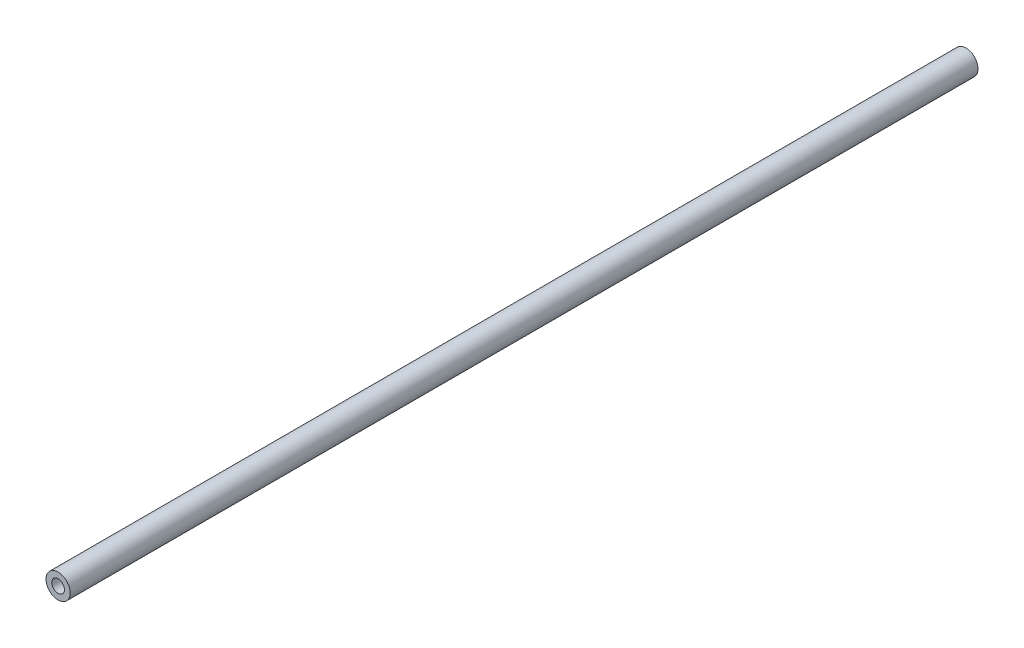
from build123d import *

# Parameters (mm, degrees)
SKETCH1_R                 = 4
BOSS_EXTRUDE1_DEPTH       = 300
M5X0_8_TAPPED_HOLE1_D     = 4.2
M5X0_8_TAPPED_HOLE1_DEPTH = 10
M5X0_8_TAPPED_HOLE1_TIP   = 1.2618073


with BuildPart() as part:
    # Sketch1 → Boss-Extrude1 (new body)
    with BuildSketch(Plane.XY):
        Circle(SKETCH1_R)
    extrude(amount=-BOSS_EXTRUDE1_DEPTH)

    # M5x0.8 Tapped Hole1
    with Locations(Plane.XY):
        with Locations((0, 0)):
            Hole(M5X0_8_TAPPED_HOLE1_D / 2, depth=M5X0_8_TAPPED_HOLE1_DEPTH)
            with Locations((0, 0, -(M5X0_8_TAPPED_HOLE1_DEPTH + M5X0_8_TAPPED_HOLE1_TIP / 2))):  # 118° drill point
                Cone(0, M5X0_8_TAPPED_HOLE1_D / 2, M5X0_8_TAPPED_HOLE1_TIP, mode=Mode.SUBTRACT)


solid = part.part
